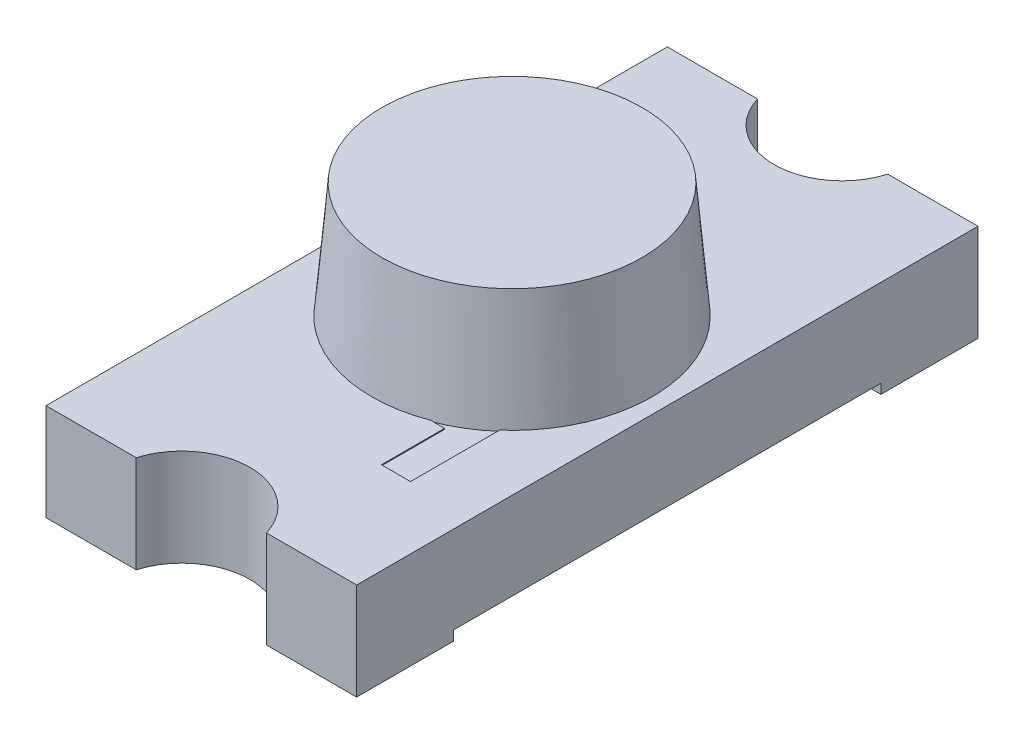
from build123d import *

# Parameters (mm, degrees)
EXTRUDE1_DEPTH      = 0.8
EXTRUDE1_DEPTH_BACK = 0.8
SKETCH2_R           = 0.35
CUT_EXTRUDE1_DEPTH  = 1.5
CUT_EXTRUDE2_DEPTH  = 0.005
SKETCH4_W           = 0.39
SKETCH4_H           = 0.39
EXTRUDE2_DEPTH      = 0.25
SKETCH5_R           = 0.722303879
EXTRUDE3_DEPTH      = 0.6
EXTRUDE3_TAPER      = 5


with BuildPart() as part:
    # Sketch1 → Extrude1 (new body, two sides)
    with BuildSketch(Plane(origin=(0, 0, 0), x_dir=(0, 0, -1), z_dir=(1, 0, 0))) as extrude1_sk:
        Polygon((1.1, 0), (1.6, 0), (1.6, 0.5), (-1.6, 0.5), (-1.6, 0), (-1.1, 0), (-1.1, 0.05), (1.1, 0.05), align=None)
    extrude(amount=EXTRUDE1_DEPTH)
    extrude(extrude1_sk.sketch, amount=-EXTRUDE1_DEPTH_BACK)

    # Sketch2 → Cut-Extrude1 (cut, through all)
    with BuildSketch(Plane(origin=(0, 0, 0), x_dir=(1, 0, 0), z_dir=(0, 1, 0))):
        with Locations((0, 1.7)):
            Circle(SKETCH2_R)
        with Locations((0, -1.7)):
            Circle(SKETCH2_R)
    extrude(amount=CUT_EXTRUDE1_DEPTH, mode=Mode.SUBTRACT)

    # Sketch3 → Cut-Extrude2 (cut)
    with BuildSketch(Plane(origin=(0, 0.5, 0), x_dir=(-1, 0, 0), z_dir=(0, 1, 0))):
        Polygon((-0.225, -0.225), (0.225, -0.225), (0.225, 0.46368555), (0.225, 0.675), (-0.327379025, 0.675), (-0.327379025, 1), (-0.477379025, 1), (-0.477379025, 0.525), (-0.279401067, 0.525), (0.075, 0.525), (0.075, 0.225), (-0.225, 0.225), align=None)
        Polygon((0.45741461, -0.450698672), (-0.276447509, -0.450698672), (-0.276447509, -0.630698672), (0.27741461, -0.630698672), (0.27741461, -1), (0.45741461, -1), align=None)
    extrude(amount=-CUT_EXTRUDE2_DEPTH, mode=Mode.SUBTRACT)

    # Sketch4 → Extrude2 (add)
    with BuildSketch(Plane(origin=(0, 0.495, 0), x_dir=(-1, 0, 0), z_dir=(0, 1, 0))):
        Rectangle(SKETCH4_W, SKETCH4_H)
    extrude(amount=EXTRUDE2_DEPTH)


with BuildPart() as body_2:
    # Sketch5 → Extrude3 (new body)
    with BuildSketch(Plane(origin=(0, 0.495, 0), x_dir=(-1, 0, 0), z_dir=(0, 1, 0))):
        Circle(SKETCH5_R)
    extrude(amount=EXTRUDE3_DEPTH, taper=EXTRUDE3_TAPER)


solid = Compound([part.part, body_2.part])
